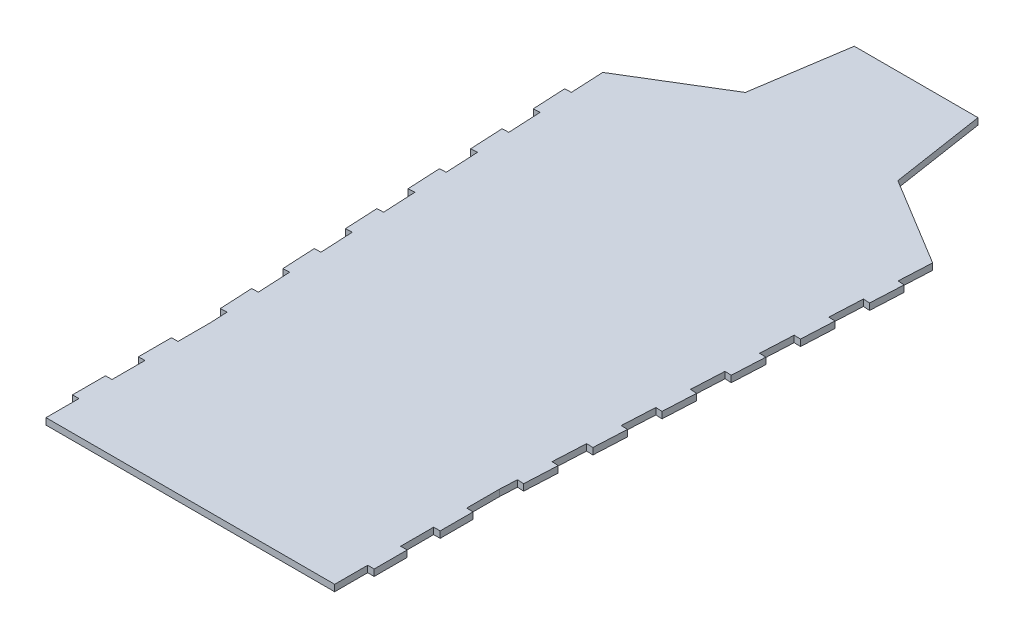
from build123d import *

# Parameters (mm, degrees)
BOSS_EXTRUDE1_DEPTH = 10


with BuildPart() as part:
    # Sketch1 → Boss-Extrude1 (new body)
    with BuildSketch(Plane(origin=(0, 0, 0), x_dir=(1, 0, 0), z_dir=(0, 1, 0))):
        Polygon((-222.25, -751.824242644), (-222.25, -802.624242644), (-232.25, -802.624242644), (-232.25, -853.424242644), (-222.25, -853.424242644), (-222.25, -904.224242644), (-232.25, -904.224242644), (-232.25, -955.024242644), (-222.25, -955.024242644), (-222.25, -1005.824242644), (222.25, -1005.824242644), (222.25, -955.024242644), (232.25, -955.024242644), (232.25, -904.224242644), (222.25, -904.224242644), (222.25, -853.424242644), (232.25, -853.424242644), (232.25, -802.624242644), (222.25, -802.624242644), (222.25, -751.824242644), (223.558028711, -725.663668424), (233.5455521, -726.163044593), (236.082383041, -675.426425778), (226.094859652, -674.927049609), (228.631690593, -624.190430794), (238.619213981, -624.689806963), (241.156044922, -573.953188148), (231.168521533, -573.453811979), (233.705352474, -522.717193164), (243.692875863, -523.216569333), (246.229706804, -472.479950518), (236.242183415, -471.980574349), (238.779014356, -421.243955534), (248.766537744, -421.743331703), (251.303368685, -371.006712888), (241.315845296, -370.507336719), (243.852676237, -319.770717904), (253.840199626, -320.270094073), (256.377030567, -269.533475258), (246.389507178, -269.034099089), (248.926338119, -218.297480274), (258.913861507, -218.796856443), (261.450692448, -168.060237628), (251.463169059, -167.560861459), (254, -116.824242644), (117.602, -33.957645835), (95.25, 111.775757356), (-95.25, 111.775757356), (-117.475, -33.759249998), (-254, -116.824242644), (-251.463169059, -167.560861459), (-261.450692448, -168.060237628), (-258.913861507, -218.796856443), (-248.926338119, -218.297480274), (-246.389507178, -269.034099089), (-256.377030567, -269.533475258), (-253.840199626, -320.270094073), (-243.852676237, -319.770717904), (-241.315845296, -370.507336719), (-251.303368685, -371.006712888), (-248.766537744, -421.743331703), (-238.779014356, -421.243955534), (-236.242183415, -471.980574349), (-246.229706804, -472.479950518), (-243.692875863, -523.216569333), (-233.705352474, -522.717193164), (-231.168521533, -573.453811979), (-241.156044922, -573.953188148), (-238.619213981, -624.689806963), (-228.631690593, -624.190430794), (-226.094859652, -674.927049609), (-236.082383041, -675.426425778), (-233.5455521, -726.163044593), (-223.558028711, -725.663668424), align=None)
    extrude(amount=BOSS_EXTRUDE1_DEPTH)


solid = part.part
